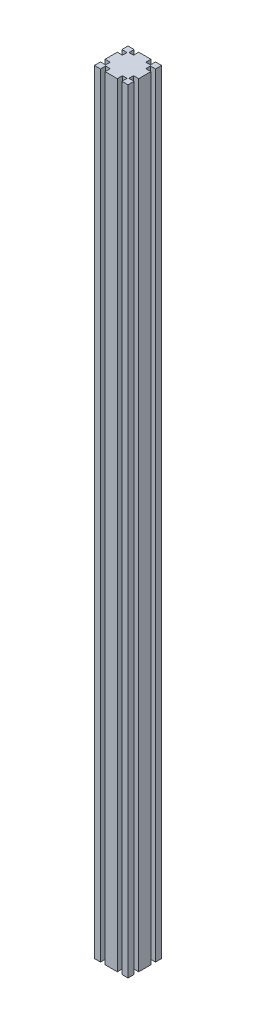
from build123d import *

# Parameters (mm, degrees)
EXTRUDE_1_DEPTH = 1380


with BuildPart() as part:
    # 草图1 → 凸台-拉伸1 (new body)
    with BuildSketch(Plane(origin=(0, 0, 0), x_dir=(1, 0, 0), z_dir=(0, 1, 0))):
        Polygon((10.9, 60), (0, 60), (0, 49.1), (9.2, 49.1), (9.2, 40.9), (0, 40.9), (0, 30), (30, 30), (30, 60), (19.1, 60), (19.1, 50.8), (10.9, 50.8), align=None)
        Polygon((30, 30), (0, 30), (0, 19.1), (9.2, 19.1), (9.2, 10.9), (0, 10.9), (0, 0), (10.9, 0), (10.9, 9.2), (19.1, 9.2), (19.1, 0), (40.9, 0), (40.9, 9.2), (49.1, 9.2), (49.1, 0), (60, 0), (60, 10.9), (50.8, 10.9), (50.8, 19.1), (60, 19.1), (60, 40.9), (50.8, 40.9), (50.8, 49.1), (60, 49.1), (60, 60), (49.1, 60), (49.1, 50.8), (40.9, 50.8), (40.9, 60), (30, 60), align=None)
    extrude(amount=EXTRUDE_1_DEPTH)


solid = part.part
